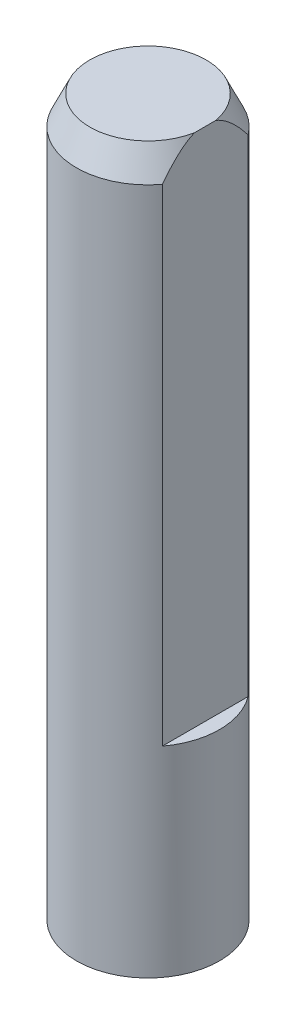
from build123d import *

# Parameters (mm, degrees)
SKETCH_1_R          = 2.5
EXTRUDE_1_DEPTH     = 25
CUT_EXTRUDE_1_DEPTH = 18
CHAMFER_1_SIZE      = 1
CHAMFER_1_SIZE2     = 0.466307658


with BuildPart() as part:
    # 草图1 → 凸台-拉伸1 (new body)
    with BuildSketch(Plane(origin=(0, 0, 0), x_dir=(1, 0, 0), z_dir=(0, 1, 0))):
        Circle(SKETCH_1_R)
    extrude(amount=EXTRUDE_1_DEPTH)

    # 草图2 → 切除-拉伸1 (cut)
    with BuildSketch(Plane(origin=(0, 25, 0), x_dir=(1, 0, 0), z_dir=(0, 1, 0))):
        Polygon((2, 2.598987806), (2, -2.361624848), (2.93708026, -2.012796341), (3.777563327, -1.758131015), (3.87416052, -0.748251275), align=None)
    extrude(amount=-CUT_EXTRUDE_1_DEPTH, mode=Mode.SUBTRACT)

    # 倒角1
    chamfer_1_edges = [part.edges().sort_by_distance(p)[0] for p in [
        (-2.5, 25, 0),
    ]]
    chamfer_1_side = [part.faces().sort_by_distance(p)[0] for p in [
        (-2.5, 12.5, 0),
    ]]
    chamfer(chamfer_1_edges, length=CHAMFER_1_SIZE, length2=CHAMFER_1_SIZE2, reference=chamfer_1_side[0])


solid = part.part
